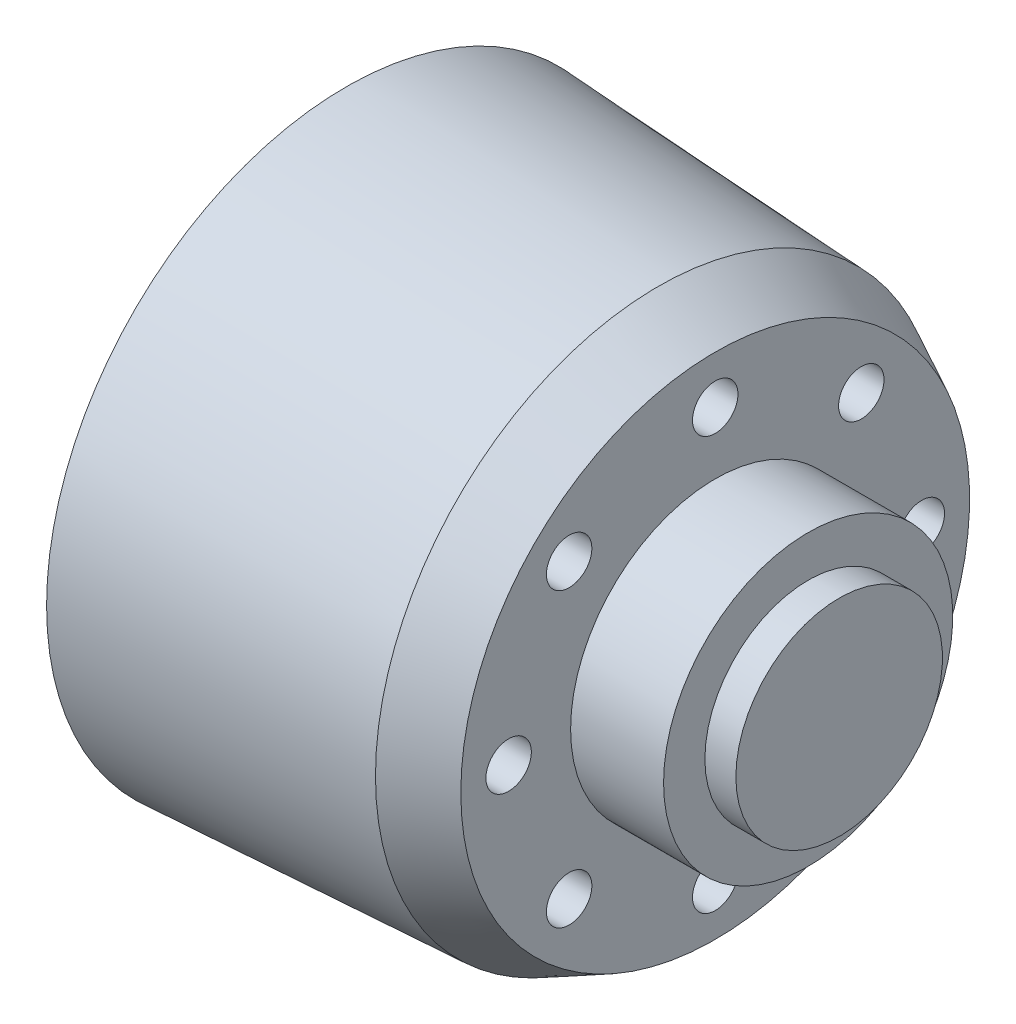
from build123d import *

# Parameters (mm, degrees)
SKETCH2_R          = 4.45
CUT_EXTRUDE1_DEPTH = 7
SKETCH3_R          = 1.1
CUT_EXTRUDE2_DEPTH = 18.866890468
SKETCH4_R          = 2.5
CUT_EXTRUDE3_DEPTH = 14.86689


with BuildPart() as part:
    # Sketch1 → Revolve1 (revolve)
    with BuildSketch(Plane(origin=(0, 0, 0), x_dir=(1, 0, 0), z_dir=(0, 1, 0))):
        Polygon((10.193859716, 12.315), (10.193859716, 7), (14.693859716, 7), (14.693859716, 5), (16.193859716, 5), (16.193859716, 0), (-7.673030752, 0), (-7.673030752, 14.5), (7.437816357, 13.69), align=None)
    revolve(axis=Axis((-18.233766234, 0, 0), (1, 0, 0)))

    # Sketch2 → Cut-Extrude1 (cut)
    with BuildSketch(Plane.ZY.offset(7.673030752)):
        Circle(SKETCH2_R)
    extrude(amount=-CUT_EXTRUDE1_DEPTH, mode=Mode.SUBTRACT)

    # Sketch3 → Cut-Extrude2 (cut, through all)
    with BuildSketch(Plane(origin=(10.193859716, 0, 0), x_dir=(0, 0, -1), z_dir=(1, 0, 0))):
        with Locations((0, 10)):
            Circle(SKETCH3_R)
        with Locations((7.071067812, 7.071067812)):
            Circle(SKETCH3_R)
        with Locations((10, 0)):
            Circle(SKETCH3_R)
        with Locations((7.071067812, -7.071067812)):
            Circle(SKETCH3_R)
        with Locations((0, -10)):
            Circle(SKETCH3_R)
        with Locations((-7.071067812, -7.071067812)):
            Circle(SKETCH3_R)
        with Locations((-10, 0)):
            Circle(SKETCH3_R)
        with Locations((-7.071067812, 7.071067812)):
            Circle(SKETCH3_R)
    extrude(amount=-CUT_EXTRUDE2_DEPTH, mode=Mode.SUBTRACT)

    # Sketch4 → Cut-Extrude3 (cut)
    with BuildSketch(Plane.ZY.offset(7.673030752)):
        with Locations((0, 10)):
            Circle(SKETCH4_R)
        with Locations((7.071067812, 7.071067812)):
            Circle(SKETCH4_R)
        with Locations((10, 0)):
            Circle(SKETCH4_R)
        with Locations((7.071067812, -7.071067812)):
            Circle(SKETCH4_R)
        with Locations((0, -10)):
            Circle(SKETCH4_R)
        with Locations((-7.071067812, -7.071067812)):
            Circle(SKETCH4_R)
        with Locations((-10, 0)):
            Circle(SKETCH4_R)
        with Locations((-7.071067812, 7.071067812)):
            Circle(SKETCH4_R)
    extrude(amount=-CUT_EXTRUDE3_DEPTH, mode=Mode.SUBTRACT)


solid = part.part
